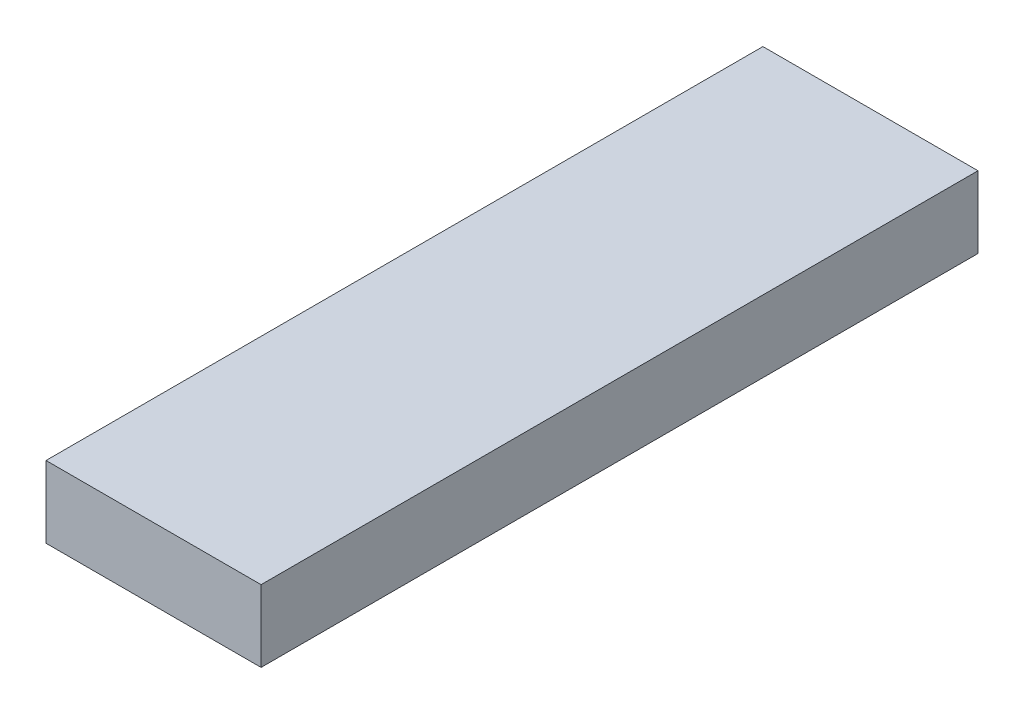
from build123d import *

# Parameters (mm, degrees)
SKETCH1_W           = 9
SKETCH1_H           = 3
BOSS_EXTRUDE1_DEPTH = 30


with BuildPart() as part:
    # Sketch1 → Boss-Extrude1 (new body)
    with BuildSketch(Plane.XY):
        with Locations((4.5, 1.5)):
            Rectangle(SKETCH1_W, SKETCH1_H)
    extrude(amount=BOSS_EXTRUDE1_DEPTH)


solid = part.part
